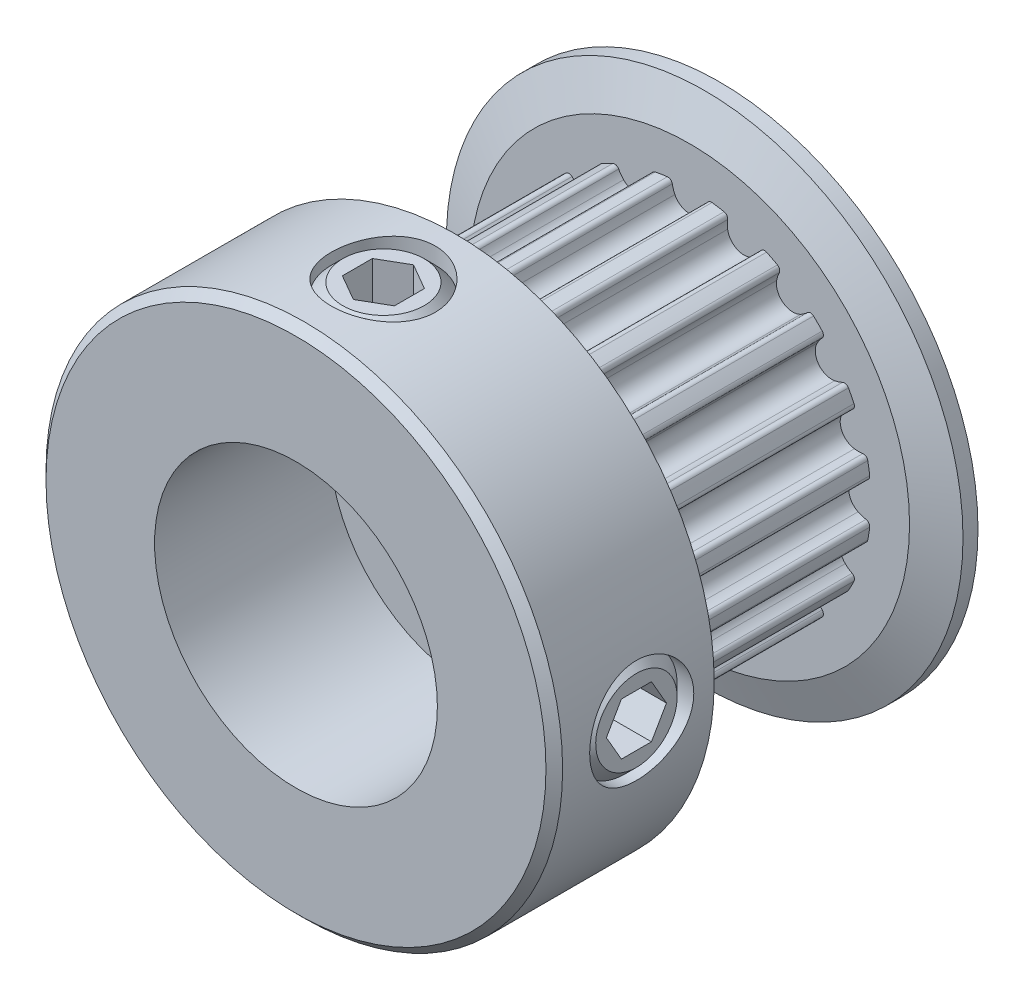
from build123d import *

# Parameters (mm, degrees)
CUT_EXTRUDE1_START = 1.245
CUT_EXTRUDE1_DEPTH = 7.37
CIRPATTERN1_COUNT  = 20
SKETCH4_R          = 1.7526
CUT_EXTRUDE2_DEPTH = 15.22219482
CUT_EXTRUDE3_DEPTH = 1.31445
CIRPATTERN3_COUNT  = 2
CIRPATTERN3_ANGLE  = 90
CHAMFER1_SIZE      = 0.28075
SKETCH7_R          = 4.7625
CUT_EXTRUDE4_DEPTH = 5.89


with BuildPart() as part:
    # Sketch2 → Revolve1 (revolve)
    with BuildSketch(Plane(origin=(0, 0, 0), x_dir=(0, 0, -1), z_dir=(1, 0, 0)), mode=Mode.PRIVATE) as revolve1_sk:
        Polygon((-7.135, 3.175), (7.135, 3.175), (7.135, 8.6995), (6.63, 8.6995), (6.125, 7.404), (6.125, 6.1085), (-1.245, 6.1085), (-1.245, 7.404), (-1.75, 8.6995), (-7.135, 8.6995), align=None)
    revolve(revolve1_sk.sketch.rotate(Axis((0, 0, 7.135), (0, 0, -1)), 90), axis=Axis((0, 0, 7.135), (0, 0, -1)))

    # Sketch3 → Cut-Extrude1 (cut)
    with BuildSketch(Plane.XY.offset(CUT_EXTRUDE1_START)):
        with BuildLine():
            Line((2.840989707, 8.6995), (-2.840989707, 8.6995))
            Line((-2.840989707, 8.6995), (-1.896292335, 5.806707124))
            ThreePointArc((-1.896292335, 5.806707124), (-1.330166224, 5.961914966), (-0.751756185, 6.062065233))
            ThreePointArc((-0.751756185, 6.062065233), (-0.643911332, 6.033664451), (-0.58547487, 5.93867868))
            ThreePointArc((-0.58547487, 5.93867868), (-0.551683777, 5.801420225), (-0.498876404, 5.670297753))
            ThreePointArc((-0.498876404, 5.670297753), (0, 5.3585), (0.498876404, 5.670297753))
            ThreePointArc((0.498876404, 5.670297753), (0.551683777, 5.801420225), (0.58547487, 5.93867868))
            ThreePointArc((0.58547487, 5.93867868), (0.643911332, 6.033664451), (0.751756185, 6.062065233))
            ThreePointArc((0.751756185, 6.062065233), (1.330166224, 5.961914966), (1.896292335, 5.806707124))
            Line((1.896292335, 5.806707124), (2.840989707, 8.6995))
        make_face()
    cut_extrude1 = extrude(amount=-CUT_EXTRUDE1_DEPTH, mode=Mode.SUBTRACT)

    # CirPattern1: Cut-Extrude1 ×20 about axis
    cirpattern1_axis = Axis((0, 0, 0), (0, 0, 1))
    for i in range(1, CIRPATTERN1_COUNT):
        add(cut_extrude1.rotate(cirpattern1_axis, i * 360 / CIRPATTERN1_COUNT), mode=Mode.SUBTRACT)

    # Sketch4 → Cut-Extrude2 (cut, through all)
    with BuildSketch(Plane(origin=(0, 0, 0), x_dir=(0, -1, 0), z_dir=(1, 0, 0))):
        with Locations(Location((0, -4.19, 0), (0, 0, 270))):
            Circle(SKETCH4_R)
    cut_extrude2 = extrude(amount=CUT_EXTRUDE2_DEPTH, mode=Mode.SUBTRACT)

    # Sketch5 → Revolve2 (revolve)
    with BuildSketch(Plane.XY.offset(4.19), mode=Mode.PRIVATE) as revolve2_sk:
        Polygon((3.175, -1.3716), (3.175, 0), (8.521132172, 0), (8.521132172, -1.3716), (8.140132172, -1.7526), (3.556, -1.7526), align=None)
    revolve2 = revolve(revolve2_sk.sketch.rotate(Axis((3.175, 0, 4.19), (1, 0, 0)), 270), axis=Axis((3.175, 0, 4.19), (1, 0, 0)))

    # Sketch6 → Cut-Extrude3 (cut)
    with BuildSketch(Plane(origin=(8.521132172, 5.384140679, 0), x_dir=(0, -1, 0), z_dir=(-1, 0, 0))):
        Polygon((5.384140679, 5.201864082), (4.507840679, 4.695932041), (4.507840679, 3.684067959), (5.384140679, 3.178135918), (6.260440679, 3.684067959), (6.260440679, 4.695932041), align=None)
    cut_extrude3 = extrude(amount=CUT_EXTRUDE3_DEPTH, mode=Mode.SUBTRACT)

    # CirPattern3: Cut-Extrude2, Revolve2, Cut-Extrude3 ×2 about axis
    cirpattern3_axis = Axis((0, 0, 0), (0, 0, 1))
    add([cut_extrude2.rotate(cirpattern3_axis, i * CIRPATTERN3_ANGLE / (CIRPATTERN3_COUNT - 1)) for i in range(1, CIRPATTERN3_COUNT)], mode=Mode.SUBTRACT)
    add([revolve2.rotate(cirpattern3_axis, i * CIRPATTERN3_ANGLE / (CIRPATTERN3_COUNT - 1)) for i in range(1, CIRPATTERN3_COUNT)])
    add([cut_extrude3.rotate(cirpattern3_axis, i * CIRPATTERN3_ANGLE / (CIRPATTERN3_COUNT - 1)) for i in range(1, CIRPATTERN3_COUNT)], mode=Mode.SUBTRACT)

    # Chamfer1
    chamfer1_edges = [part.edges().sort_by_distance(p)[0] for p in [
        (-3.175, 0, 7.135),
        (-8.6995, 0, 7.135),
    ]]
    chamfer(chamfer1_edges, length=CHAMFER1_SIZE)

    # Sketch7 → Cut-Extrude4 (cut)
    with BuildSketch(Plane.XY.offset(7.135)):
        Circle(SKETCH7_R)
    extrude(amount=-CUT_EXTRUDE4_DEPTH, mode=Mode.SUBTRACT)


solid = part.part
